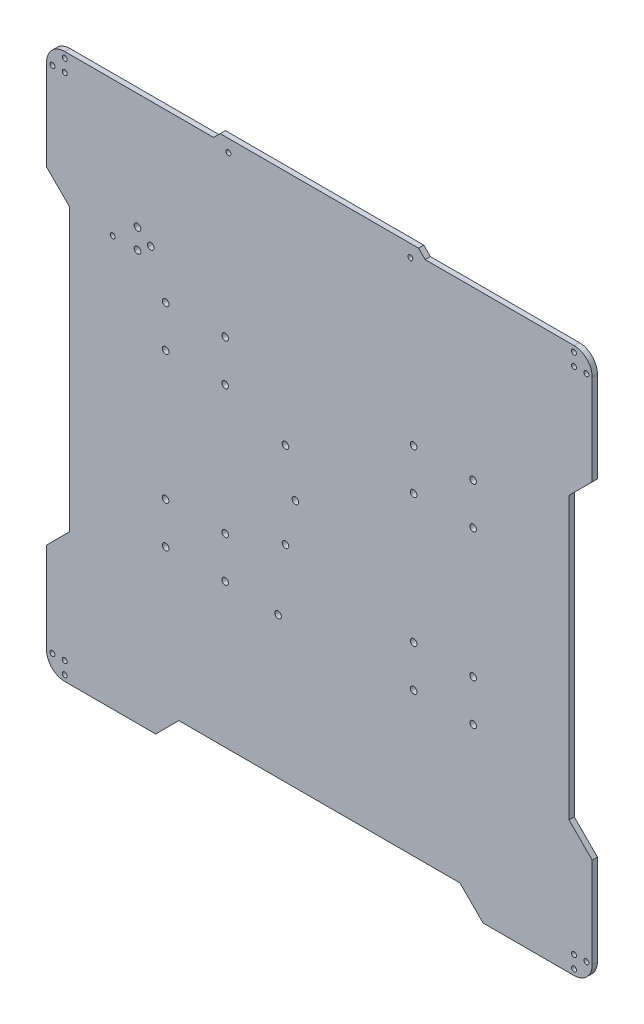
from build123d import *

# Parameters (mm, degrees)
SKETCH1_R           = 2
SKETCH1_R_2         = 1.5
BOSS_EXTRUDE1_DEPTH = 3.175


with BuildPart() as part:
    # Sketch1 → Boss-Extrude1 (new body)
    with BuildSketch(Plane.XY):
        with BuildLine():
            Line((165, 154), (165, 99))
            Line((165, 99), (151, 85))
            Line((151, 85), (151, -85))
            Line((151, -85), (165, -99))
            Line((165, -99), (165, -154))
            ThreePointArc((165, -154), (161.778174593, -161.778174593), (154, -165))
            Line((154, -165), (99, -165))
            Line((99, -165), (85, -151))
            Line((85, -151), (-85, -151))
            Line((-85, -151), (-99, -165))
            Line((-99, -165), (-154, -165))
            ThreePointArc((-154, -165), (-161.778174593, -161.778174593), (-165, -154))
            Line((-165, -154), (-165, -99))
            Line((-165, -99), (-151, -85))
            Line((-151, -85), (-151, 85))
            Line((-151, 85), (-165, 99))
            Line((-165, 99), (-165, 154))
            ThreePointArc((-165, 154), (-161.778174593, 161.778174593), (-154, 165))
            Line((-154, 165), (-64, 165))
            Line((-64, 165), (-60, 169))
            Line((-60, 169), (60, 169))
            Line((60, 169), (64, 165))
            Line((64, 165), (154, 165))
            ThreePointArc((154, 165), (161.778174593, 161.778174593), (165, 154))
        make_face()
        with Locations((-14.5, -0.5)):
            Circle(SKETCH1_R, mode=Mode.SUBTRACT)
        with Locations((-93, 64)):
            Circle(SKETCH1_R, mode=Mode.SUBTRACT)
        with Locations((-93, 39)):
            Circle(SKETCH1_R, mode=Mode.SUBTRACT)
        with Locations((-57, 39)):
            Circle(SKETCH1_R, mode=Mode.SUBTRACT)
        with Locations((-57, 64)):
            Circle(SKETCH1_R, mode=Mode.SUBTRACT)
        with Locations((57, 39)):
            Circle(SKETCH1_R, mode=Mode.SUBTRACT)
        with Locations((57, 64)):
            Circle(SKETCH1_R, mode=Mode.SUBTRACT)
        with Locations((93, 39)):
            Circle(SKETCH1_R, mode=Mode.SUBTRACT)
        with Locations((93, 64)):
            Circle(SKETCH1_R, mode=Mode.SUBTRACT)
        with Locations((57, -64)):
            Circle(SKETCH1_R, mode=Mode.SUBTRACT)
        with Locations((57, -39)):
            Circle(SKETCH1_R, mode=Mode.SUBTRACT)
        with Locations((93, -39)):
            Circle(SKETCH1_R, mode=Mode.SUBTRACT)
        with Locations((93, -64)):
            Circle(SKETCH1_R, mode=Mode.SUBTRACT)
        with Locations((-93, -64)):
            Circle(SKETCH1_R, mode=Mode.SUBTRACT)
        with Locations((-57, -64)):
            Circle(SKETCH1_R, mode=Mode.SUBTRACT)
        with Locations((-57, -39)):
            Circle(SKETCH1_R, mode=Mode.SUBTRACT)
        with Locations((-93, -39)):
            Circle(SKETCH1_R, mode=Mode.SUBTRACT)
        with Locations((-20.5, -26.5)):
            Circle(SKETCH1_R, mode=Mode.SUBTRACT)
        with Locations((-161.5, 154)):
            Circle(SKETCH1_R_2, mode=Mode.SUBTRACT)
        with Locations((-154, 161.5)):
            Circle(SKETCH1_R_2, mode=Mode.SUBTRACT)
        with Locations((154, 161.5)):
            Circle(SKETCH1_R_2, mode=Mode.SUBTRACT)
        with Locations((161.5, 154)):
            Circle(SKETCH1_R_2, mode=Mode.SUBTRACT)
        with Locations((161.5, -154)):
            Circle(SKETCH1_R_2, mode=Mode.SUBTRACT)
        with Locations((-20.5, 25.5)):
            Circle(SKETCH1_R, mode=Mode.SUBTRACT)
        with Locations((-25, -65.5)):
            Circle(SKETCH1_R, mode=Mode.SUBTRACT)
        with Locations((154, -161.5)):
            Circle(SKETCH1_R_2, mode=Mode.SUBTRACT)
        with Locations((-161.5, -154)):
            Circle(SKETCH1_R_2, mode=Mode.SUBTRACT)
        with Locations((-154, -161.5)):
            Circle(SKETCH1_R_2, mode=Mode.SUBTRACT)
        with Locations((-110, 95)):
            Circle(SKETCH1_R, mode=Mode.SUBTRACT)
        with Locations((-110, 83)):
            Circle(SKETCH1_R, mode=Mode.SUBTRACT)
        with Locations((-102, 89)):
            Circle(SKETCH1_R, mode=Mode.SUBTRACT)
        with Locations((-125, 83)):
            Circle(SKETCH1_R_2, mode=Mode.SUBTRACT)
        with Locations((-154, 154)):
            Circle(SKETCH1_R_2, mode=Mode.SUBTRACT)
        with Locations((154, 154)):
            Circle(SKETCH1_R_2, mode=Mode.SUBTRACT)
        with Locations((154, -154)):
            Circle(SKETCH1_R_2, mode=Mode.SUBTRACT)
        with Locations((-154, -154)):
            Circle(SKETCH1_R_2, mode=Mode.SUBTRACT)
        with Locations((-55, 161.5)):
            Circle(SKETCH1_R_2, mode=Mode.SUBTRACT)
        with Locations((55, 161.5)):
            Circle(SKETCH1_R_2, mode=Mode.SUBTRACT)
    extrude(amount=BOSS_EXTRUDE1_DEPTH)


solid = part.part
